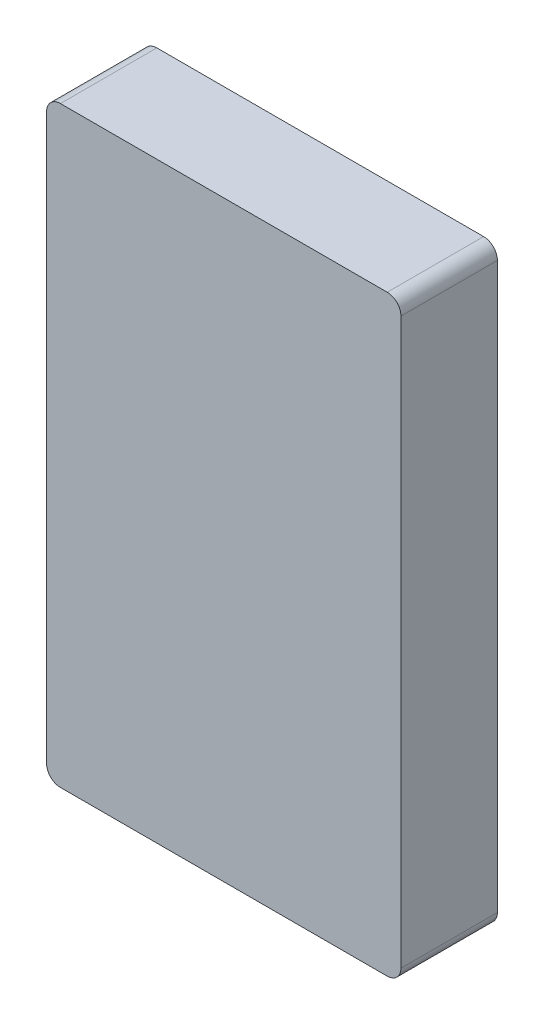
from build123d import *

# Parameters (mm, degrees)
BOSS_EXTRUDE2_DEPTH = 44.45
SKETCH3_R           = 1.5875
CUT_EXTRUDE1_DEPTH  = 6.35


with BuildPart() as part:
    # Model → Boss-Extrude2 (new body)
    with BuildSketch(Plane.XY):
        with BuildLine():
            Line((-114.7858004, -1481.0994), (-114.7858004, -1220.7494))
            ThreePointArc((-114.7858004, -1220.7494), (-116.645672339, -1216.259271939), (-121.1358004, -1214.3994))
            Line((-121.1358004, -1214.3994), (-271.8000406, -1214.3994))
            ThreePointArc((-271.8000406, -1214.3994), (-276.290168661, -1216.259271939), (-278.1500406, -1220.7494))
            Line((-278.1500406, -1220.7494), (-278.1500406, -1481.0994))
            ThreePointArc((-278.1500406, -1481.0994), (-276.290168661, -1485.589528061), (-271.8000406, -1487.4494))
            Line((-271.8000406, -1487.4494), (-121.1358004, -1487.4494))
            ThreePointArc((-121.1358004, -1487.4494), (-116.645672339, -1485.589528061), (-114.7858004, -1481.0994))
        make_face()
    extrude(amount=BOSS_EXTRUDE2_DEPTH)

    # Sketch3 → Cut-Extrude1 (cut)
    with BuildSketch(Plane(origin=(0, 0, 0), x_dir=(-1, 0, 0), z_dir=(0, 0, -1))):
        with Locations((187.835413, -1275.2256944)):
            Circle(SKETCH3_R)
        with Locations((181.485413, -1275.2256944)):
            Circle(SKETCH3_R)
        with Locations((194.185413, -1275.2256944)):
            Circle(SKETCH3_R)
        with Locations((187.835413, -1268.8756944)):
            Circle(SKETCH3_R)
        with Locations((181.485413, -1268.8756944)):
            Circle(SKETCH3_R)
        with Locations((194.185413, -1268.8756944)):
            Circle(SKETCH3_R)
        with Locations((187.835413, -1262.5256944)):
            Circle(SKETCH3_R)
        with Locations((181.485413, -1262.5256944)):
            Circle(SKETCH3_R)
        with Locations((194.185413, -1262.5256944)):
            Circle(SKETCH3_R)
        with Locations((187.835413, -1256.1756944)):
            Circle(SKETCH3_R)
        with Locations((181.485413, -1256.1756944)):
            Circle(SKETCH3_R)
        with Locations((194.185413, -1256.1756944)):
            Circle(SKETCH3_R)
        with Locations((187.835413, -1281.5756944)):
            Circle(SKETCH3_R)
        with Locations((181.485413, -1281.5756944)):
            Circle(SKETCH3_R)
        with Locations((194.185413, -1281.5756944)):
            Circle(SKETCH3_R)
        with Locations((132.3624226, -1274.5006514)):
            Circle(SKETCH3_R)
        with Locations((126.0124226, -1274.5006514)):
            Circle(SKETCH3_R)
        with Locations((138.7124226, -1274.5006514)):
            Circle(SKETCH3_R)
        with Locations((132.3624226, -1268.1506514)):
            Circle(SKETCH3_R)
        with Locations((126.0124226, -1268.1506514)):
            Circle(SKETCH3_R)
        with Locations((138.7124226, -1268.1506514)):
            Circle(SKETCH3_R)
        with Locations((132.3624226, -1261.8006514)):
            Circle(SKETCH3_R)
        with Locations((126.0124226, -1261.8006514)):
            Circle(SKETCH3_R)
        with Locations((138.7124226, -1261.8006514)):
            Circle(SKETCH3_R)
        with Locations((132.3624226, -1255.4506514)):
            Circle(SKETCH3_R)
        with Locations((126.0124226, -1255.4506514)):
            Circle(SKETCH3_R)
        with Locations((138.7124226, -1255.4506514)):
            Circle(SKETCH3_R)
        with Locations((132.3624226, -1280.8506514)):
            Circle(SKETCH3_R)
        with Locations((126.0124226, -1280.8506514)):
            Circle(SKETCH3_R)
        with Locations((138.7124226, -1280.8506514)):
            Circle(SKETCH3_R)
        with Locations((262.0453992, -1275.2256944)):
            Circle(SKETCH3_R)
        with Locations((255.6953992, -1275.2256944)):
            Circle(SKETCH3_R)
        with Locations((268.3953992, -1275.2256944)):
            Circle(SKETCH3_R)
        with Locations((262.0453992, -1268.8756944)):
            Circle(SKETCH3_R)
        with Locations((255.6953992, -1268.8756944)):
            Circle(SKETCH3_R)
        with Locations((268.3953992, -1268.8756944)):
            Circle(SKETCH3_R)
        with Locations((262.0453992, -1262.5256944)):
            Circle(SKETCH3_R)
        with Locations((255.6953992, -1262.5256944)):
            Circle(SKETCH3_R)
        with Locations((268.3953992, -1262.5256944)):
            Circle(SKETCH3_R)
        with Locations((262.0453992, -1256.1756944)):
            Circle(SKETCH3_R)
        with Locations((255.6953992, -1256.1756944)):
            Circle(SKETCH3_R)
        with Locations((268.3953992, -1256.1756944)):
            Circle(SKETCH3_R)
        with Locations((262.0453992, -1281.5756944)):
            Circle(SKETCH3_R)
        with Locations((255.6953992, -1281.5756944)):
            Circle(SKETCH3_R)
        with Locations((268.3953992, -1281.5756944)):
            Circle(SKETCH3_R)
        with Locations((211.081112, -1476.7057842)):
            Circle(SKETCH3_R)
        with Locations((211.71535, -1470.3875596)):
            Circle(SKETCH3_R)
        with Locations((210.446874, -1483.0240342)):
            Circle(SKETCH3_R)
        with Locations((218.06535, -1476.7375596)):
            Circle(SKETCH3_R)
        with Locations((218.06535, -1470.3875596)):
            Circle(SKETCH3_R)
        with Locations((218.06535, -1483.0875596)):
            Circle(SKETCH3_R)
        with Locations((229.0370832, -1476.2635702)):
            Circle(SKETCH3_R)
        with Locations((229.0370832, -1469.9135702)):
            Circle(SKETCH3_R)
        with Locations((229.0370832, -1482.6135702)):
            Circle(SKETCH3_R)
        with Locations((235.913549, -1476.2417008)):
            Circle(SKETCH3_R)
        with Locations((235.3870832, -1469.9135702)):
            Circle(SKETCH3_R)
        with Locations((236.4399894, -1482.5698314)):
            Circle(SKETCH3_R)
        with Locations((203.8965442, -1475.3608034)):
            Circle(SKETCH3_R)
        with Locations((205.36535, -1469.1830154)):
            Circle(SKETCH3_R)
        with Locations((202.4277638, -1481.5385914)):
            Circle(SKETCH3_R)
        with Locations((222.2470536, -1226.1652896)):
            Circle(SKETCH3_R)
        with Locations((222.2470536, -1232.5152896)):
            Circle(SKETCH3_R)
        with Locations((222.2470536, -1219.8152896)):
            Circle(SKETCH3_R)
        with Locations((215.8970536, -1226.1652896)):
            Circle(SKETCH3_R)
        with Locations((215.8970536, -1232.5152896)):
            Circle(SKETCH3_R)
        with Locations((215.8970536, -1219.8152896)):
            Circle(SKETCH3_R)
        with Locations((209.5470536, -1226.1652896)):
            Circle(SKETCH3_R)
        with Locations((209.5470536, -1232.5152896)):
            Circle(SKETCH3_R)
        with Locations((209.5470536, -1219.8152896)):
            Circle(SKETCH3_R)
        with Locations((203.1970536, -1226.1652896)):
            Circle(SKETCH3_R)
        with Locations((203.1970536, -1232.5152896)):
            Circle(SKETCH3_R)
        with Locations((203.1970536, -1219.8152896)):
            Circle(SKETCH3_R)
        with Locations((228.5970536, -1226.1652896)):
            Circle(SKETCH3_R)
        with Locations((228.5970536, -1232.5152896)):
            Circle(SKETCH3_R)
        with Locations((228.5970536, -1219.8152896)):
            Circle(SKETCH3_R)
        with Locations((186.1002882, -1226.4472042)):
            Circle(SKETCH3_R)
        with Locations((186.1002882, -1232.7972042)):
            Circle(SKETCH3_R)
        with Locations((186.1002882, -1220.0972042)):
            Circle(SKETCH3_R)
        with Locations((179.7502882, -1226.4472042)):
            Circle(SKETCH3_R)
        with Locations((179.7502882, -1232.7972042)):
            Circle(SKETCH3_R)
        with Locations((179.7502882, -1220.0972042)):
            Circle(SKETCH3_R)
        with Locations((173.4002882, -1226.4472042)):
            Circle(SKETCH3_R)
        with Locations((173.4002882, -1232.7972042)):
            Circle(SKETCH3_R)
        with Locations((173.4002882, -1220.0972042)):
            Circle(SKETCH3_R)
        with Locations((167.0502882, -1226.4472042)):
            Circle(SKETCH3_R)
        with Locations((167.0502882, -1232.7972042)):
            Circle(SKETCH3_R)
        with Locations((167.0502882, -1220.0972042)):
            Circle(SKETCH3_R)
        with Locations((192.4502882, -1226.4472042)):
            Circle(SKETCH3_R)
        with Locations((192.4502882, -1232.7972042)):
            Circle(SKETCH3_R)
        with Locations((192.4502882, -1220.0972042)):
            Circle(SKETCH3_R)
        with Locations((187.835413, -1309.4276326)):
            Circle(SKETCH3_R)
        with Locations((181.485413, -1309.4276326)):
            Circle(SKETCH3_R)
        with Locations((194.185413, -1309.4276326)):
            Circle(SKETCH3_R)
        with Locations((187.835413, -1303.0776326)):
            Circle(SKETCH3_R)
        with Locations((181.485413, -1303.0776326)):
            Circle(SKETCH3_R)
        with Locations((194.185413, -1303.0776326)):
            Circle(SKETCH3_R)
        with Locations((187.835413, -1296.7276326)):
            Circle(SKETCH3_R)
        with Locations((181.485413, -1296.7276326)):
            Circle(SKETCH3_R)
        with Locations((194.185413, -1296.7276326)):
            Circle(SKETCH3_R)
        with Locations((187.835413, -1290.3776326)):
            Circle(SKETCH3_R)
        with Locations((181.485413, -1290.3776326)):
            Circle(SKETCH3_R)
        with Locations((194.185413, -1290.3776326)):
            Circle(SKETCH3_R)
        with Locations((187.835413, -1315.7776326)):
            Circle(SKETCH3_R)
        with Locations((181.485413, -1315.7776326)):
            Circle(SKETCH3_R)
        with Locations((194.185413, -1315.7776326)):
            Circle(SKETCH3_R)
        with Locations((132.3624226, -1308.7025896)):
            Circle(SKETCH3_R)
        with Locations((126.0124226, -1308.7025896)):
            Circle(SKETCH3_R)
        with Locations((138.7124226, -1308.7025896)):
            Circle(SKETCH3_R)
        with Locations((132.3624226, -1302.3525896)):
            Circle(SKETCH3_R)
        with Locations((126.0124226, -1302.3525896)):
            Circle(SKETCH3_R)
        with Locations((138.7124226, -1302.3525896)):
            Circle(SKETCH3_R)
        with Locations((132.3624226, -1296.0025896)):
            Circle(SKETCH3_R)
        with Locations((126.0124226, -1296.0025896)):
            Circle(SKETCH3_R)
        with Locations((138.7124226, -1296.0025896)):
            Circle(SKETCH3_R)
        with Locations((132.3624226, -1289.6525896)):
            Circle(SKETCH3_R)
        with Locations((126.0124226, -1289.6525896)):
            Circle(SKETCH3_R)
        with Locations((138.7124226, -1289.6525896)):
            Circle(SKETCH3_R)
        with Locations((132.3624226, -1315.0525896)):
            Circle(SKETCH3_R)
        with Locations((126.0124226, -1315.0525896)):
            Circle(SKETCH3_R)
        with Locations((138.7124226, -1315.0525896)):
            Circle(SKETCH3_R)
        with Locations((262.0453992, -1309.4276326)):
            Circle(SKETCH3_R)
        with Locations((255.6953992, -1309.4276326)):
            Circle(SKETCH3_R)
        with Locations((268.3953992, -1309.4276326)):
            Circle(SKETCH3_R)
        with Locations((262.0453992, -1303.0776326)):
            Circle(SKETCH3_R)
        with Locations((255.6953992, -1303.0776326)):
            Circle(SKETCH3_R)
        with Locations((268.3953992, -1303.0776326)):
            Circle(SKETCH3_R)
        with Locations((262.0453992, -1296.7276326)):
            Circle(SKETCH3_R)
        with Locations((255.6953992, -1296.7276326)):
            Circle(SKETCH3_R)
        with Locations((268.3953992, -1296.7276326)):
            Circle(SKETCH3_R)
        with Locations((262.0453992, -1290.3776326)):
            Circle(SKETCH3_R)
        with Locations((255.6953992, -1290.3776326)):
            Circle(SKETCH3_R)
        with Locations((268.3953992, -1290.3776326)):
            Circle(SKETCH3_R)
        with Locations((262.0453992, -1315.7776326)):
            Circle(SKETCH3_R)
        with Locations((255.6953992, -1315.7776326)):
            Circle(SKETCH3_R)
        with Locations((268.3953992, -1315.7776326)):
            Circle(SKETCH3_R)
        with Locations((187.835413, -1344.9876326)):
            Circle(SKETCH3_R)
        with Locations((181.485413, -1344.9876326)):
            Circle(SKETCH3_R)
        with Locations((194.185413, -1344.9876326)):
            Circle(SKETCH3_R)
        with Locations((187.835413, -1338.6376326)):
            Circle(SKETCH3_R)
        with Locations((181.485413, -1338.6376326)):
            Circle(SKETCH3_R)
        with Locations((194.185413, -1338.6376326)):
            Circle(SKETCH3_R)
        with Locations((187.835413, -1332.2876326)):
            Circle(SKETCH3_R)
        with Locations((181.485413, -1332.2876326)):
            Circle(SKETCH3_R)
        with Locations((194.185413, -1332.2876326)):
            Circle(SKETCH3_R)
        with Locations((187.835413, -1325.9376326)):
            Circle(SKETCH3_R)
        with Locations((181.485413, -1325.9376326)):
            Circle(SKETCH3_R)
        with Locations((194.185413, -1325.9376326)):
            Circle(SKETCH3_R)
        with Locations((187.835413, -1351.3376326)):
            Circle(SKETCH3_R)
        with Locations((181.485413, -1351.3376326)):
            Circle(SKETCH3_R)
        with Locations((194.185413, -1351.3376326)):
            Circle(SKETCH3_R)
        with Locations((132.3624226, -1344.2625896)):
            Circle(SKETCH3_R)
        with Locations((126.0124226, -1344.2625896)):
            Circle(SKETCH3_R)
        with Locations((138.7124226, -1344.2625896)):
            Circle(SKETCH3_R)
        with Locations((132.3624226, -1337.9125896)):
            Circle(SKETCH3_R)
        with Locations((126.0124226, -1337.9125896)):
            Circle(SKETCH3_R)
        with Locations((138.7124226, -1337.9125896)):
            Circle(SKETCH3_R)
        with Locations((132.3624226, -1331.5625896)):
            Circle(SKETCH3_R)
        with Locations((126.0124226, -1331.5625896)):
            Circle(SKETCH3_R)
        with Locations((138.7124226, -1331.5625896)):
            Circle(SKETCH3_R)
        with Locations((132.3624226, -1325.2125896)):
            Circle(SKETCH3_R)
        with Locations((126.0124226, -1325.2125896)):
            Circle(SKETCH3_R)
        with Locations((138.7124226, -1325.2125896)):
            Circle(SKETCH3_R)
        with Locations((132.3624226, -1350.6125896)):
            Circle(SKETCH3_R)
        with Locations((126.0124226, -1350.6125896)):
            Circle(SKETCH3_R)
        with Locations((138.7124226, -1350.6125896)):
            Circle(SKETCH3_R)
        with Locations((262.0453992, -1344.9876326)):
            Circle(SKETCH3_R)
        with Locations((255.6953992, -1344.9876326)):
            Circle(SKETCH3_R)
        with Locations((268.3953992, -1344.9876326)):
            Circle(SKETCH3_R)
        with Locations((262.0453992, -1338.6376326)):
            Circle(SKETCH3_R)
        with Locations((255.6953992, -1338.6376326)):
            Circle(SKETCH3_R)
        with Locations((268.3953992, -1338.6376326)):
            Circle(SKETCH3_R)
        with Locations((262.0453992, -1332.2876326)):
            Circle(SKETCH3_R)
        with Locations((255.6953992, -1332.2876326)):
            Circle(SKETCH3_R)
        with Locations((268.3953992, -1332.2876326)):
            Circle(SKETCH3_R)
        with Locations((262.0453992, -1325.9376326)):
            Circle(SKETCH3_R)
        with Locations((255.6953992, -1325.9376326)):
            Circle(SKETCH3_R)
        with Locations((268.3953992, -1325.9376326)):
            Circle(SKETCH3_R)
        with Locations((262.0453992, -1351.3376326)):
            Circle(SKETCH3_R)
        with Locations((255.6953992, -1351.3376326)):
            Circle(SKETCH3_R)
        with Locations((268.3953992, -1351.3376326)):
            Circle(SKETCH3_R)
        with Locations((187.835413, -1380.5476326)):
            Circle(SKETCH3_R)
        with Locations((181.485413, -1380.5476326)):
            Circle(SKETCH3_R)
        with Locations((194.185413, -1380.5476326)):
            Circle(SKETCH3_R)
        with Locations((187.835413, -1374.1976326)):
            Circle(SKETCH3_R)
        with Locations((181.485413, -1374.1976326)):
            Circle(SKETCH3_R)
        with Locations((194.185413, -1374.1976326)):
            Circle(SKETCH3_R)
        with Locations((187.835413, -1367.8476326)):
            Circle(SKETCH3_R)
        with Locations((181.485413, -1367.8476326)):
            Circle(SKETCH3_R)
        with Locations((194.185413, -1367.8476326)):
            Circle(SKETCH3_R)
        with Locations((187.835413, -1361.4976326)):
            Circle(SKETCH3_R)
        with Locations((181.485413, -1361.4976326)):
            Circle(SKETCH3_R)
        with Locations((194.185413, -1361.4976326)):
            Circle(SKETCH3_R)
        with Locations((187.835413, -1386.8976326)):
            Circle(SKETCH3_R)
        with Locations((181.485413, -1386.8976326)):
            Circle(SKETCH3_R)
        with Locations((194.185413, -1386.8976326)):
            Circle(SKETCH3_R)
        with Locations((132.3624226, -1379.8225896)):
            Circle(SKETCH3_R)
        with Locations((126.0124226, -1379.8225896)):
            Circle(SKETCH3_R)
        with Locations((138.7124226, -1379.8225896)):
            Circle(SKETCH3_R)
        with Locations((132.3624226, -1373.4725896)):
            Circle(SKETCH3_R)
        with Locations((126.0124226, -1373.4725896)):
            Circle(SKETCH3_R)
        with Locations((138.7124226, -1373.4725896)):
            Circle(SKETCH3_R)
        with Locations((132.3624226, -1367.1225896)):
            Circle(SKETCH3_R)
        with Locations((126.0124226, -1367.1225896)):
            Circle(SKETCH3_R)
        with Locations((138.7124226, -1367.1225896)):
            Circle(SKETCH3_R)
        with Locations((132.3624226, -1360.7725896)):
            Circle(SKETCH3_R)
        with Locations((126.0124226, -1360.7725896)):
            Circle(SKETCH3_R)
        with Locations((138.7124226, -1360.7725896)):
            Circle(SKETCH3_R)
        with Locations((132.3624226, -1386.1725896)):
            Circle(SKETCH3_R)
        with Locations((126.0124226, -1386.1725896)):
            Circle(SKETCH3_R)
        with Locations((138.7124226, -1386.1725896)):
            Circle(SKETCH3_R)
        with Locations((262.0453992, -1380.5476326)):
            Circle(SKETCH3_R)
        with Locations((255.6953992, -1380.5476326)):
            Circle(SKETCH3_R)
        with Locations((268.3953992, -1380.5476326)):
            Circle(SKETCH3_R)
        with Locations((262.0453992, -1374.1976326)):
            Circle(SKETCH3_R)
        with Locations((255.6953992, -1374.1976326)):
            Circle(SKETCH3_R)
        with Locations((268.3953992, -1374.1976326)):
            Circle(SKETCH3_R)
        with Locations((262.0453992, -1367.8476326)):
            Circle(SKETCH3_R)
        with Locations((255.6953992, -1367.8476326)):
            Circle(SKETCH3_R)
        with Locations((268.3953992, -1367.8476326)):
            Circle(SKETCH3_R)
        with Locations((262.0453992, -1361.4976326)):
            Circle(SKETCH3_R)
        with Locations((255.6953992, -1361.4976326)):
            Circle(SKETCH3_R)
        with Locations((268.3953992, -1361.4976326)):
            Circle(SKETCH3_R)
        with Locations((262.0453992, -1386.8976326)):
            Circle(SKETCH3_R)
        with Locations((255.6953992, -1386.8976326)):
            Circle(SKETCH3_R)
        with Locations((268.3953992, -1386.8976326)):
            Circle(SKETCH3_R)
        with Locations((187.835413, -1416.1076326)):
            Circle(SKETCH3_R)
        with Locations((181.485413, -1416.1076326)):
            Circle(SKETCH3_R)
        with Locations((194.185413, -1416.1076326)):
            Circle(SKETCH3_R)
        with Locations((187.835413, -1409.7576326)):
            Circle(SKETCH3_R)
        with Locations((181.485413, -1409.7576326)):
            Circle(SKETCH3_R)
        with Locations((194.185413, -1409.7576326)):
            Circle(SKETCH3_R)
        with Locations((187.835413, -1403.4076326)):
            Circle(SKETCH3_R)
        with Locations((181.485413, -1403.4076326)):
            Circle(SKETCH3_R)
        with Locations((194.185413, -1403.4076326)):
            Circle(SKETCH3_R)
        with Locations((187.835413, -1397.0576326)):
            Circle(SKETCH3_R)
        with Locations((181.485413, -1397.0576326)):
            Circle(SKETCH3_R)
        with Locations((194.185413, -1397.0576326)):
            Circle(SKETCH3_R)
        with Locations((187.835413, -1422.4576326)):
            Circle(SKETCH3_R)
        with Locations((181.485413, -1422.4576326)):
            Circle(SKETCH3_R)
        with Locations((194.185413, -1422.4576326)):
            Circle(SKETCH3_R)
        with Locations((132.3624226, -1415.3825896)):
            Circle(SKETCH3_R)
        with Locations((126.0124226, -1415.3825896)):
            Circle(SKETCH3_R)
        with Locations((138.7124226, -1415.3825896)):
            Circle(SKETCH3_R)
        with Locations((132.3624226, -1409.0325896)):
            Circle(SKETCH3_R)
        with Locations((126.0124226, -1409.0325896)):
            Circle(SKETCH3_R)
        with Locations((138.7124226, -1409.0325896)):
            Circle(SKETCH3_R)
        with Locations((132.3624226, -1402.6825896)):
            Circle(SKETCH3_R)
        with Locations((126.0124226, -1402.6825896)):
            Circle(SKETCH3_R)
        with Locations((138.7124226, -1402.6825896)):
            Circle(SKETCH3_R)
        with Locations((132.3624226, -1396.3325896)):
            Circle(SKETCH3_R)
        with Locations((126.0124226, -1396.3325896)):
            Circle(SKETCH3_R)
        with Locations((138.7124226, -1396.3325896)):
            Circle(SKETCH3_R)
        with Locations((132.3624226, -1421.7325896)):
            Circle(SKETCH3_R)
        with Locations((126.0124226, -1421.7325896)):
            Circle(SKETCH3_R)
        with Locations((138.7124226, -1421.7325896)):
            Circle(SKETCH3_R)
        with Locations((262.0453992, -1416.1076326)):
            Circle(SKETCH3_R)
        with Locations((255.6953992, -1416.1076326)):
            Circle(SKETCH3_R)
        with Locations((268.3953992, -1416.1076326)):
            Circle(SKETCH3_R)
        with Locations((262.0453992, -1409.7576326)):
            Circle(SKETCH3_R)
        with Locations((255.6953992, -1409.7576326)):
            Circle(SKETCH3_R)
        with Locations((268.3953992, -1409.7576326)):
            Circle(SKETCH3_R)
        with Locations((262.0453992, -1403.4076326)):
            Circle(SKETCH3_R)
        with Locations((255.6953992, -1403.4076326)):
            Circle(SKETCH3_R)
        with Locations((268.3953992, -1403.4076326)):
            Circle(SKETCH3_R)
        with Locations((262.0453992, -1397.0576326)):
            Circle(SKETCH3_R)
        with Locations((255.6953992, -1397.0576326)):
            Circle(SKETCH3_R)
        with Locations((268.3953992, -1397.0576326)):
            Circle(SKETCH3_R)
        with Locations((262.0453992, -1422.4576326)):
            Circle(SKETCH3_R)
        with Locations((255.6953992, -1422.4576326)):
            Circle(SKETCH3_R)
        with Locations((268.3953992, -1422.4576326)):
            Circle(SKETCH3_R)
        with Locations((187.835413, -1451.6676326)):
            Circle(SKETCH3_R)
        with Locations((181.485413, -1451.6676326)):
            Circle(SKETCH3_R)
        with Locations((194.185413, -1451.6676326)):
            Circle(SKETCH3_R)
        with Locations((187.835413, -1445.3176326)):
            Circle(SKETCH3_R)
        with Locations((181.485413, -1445.3176326)):
            Circle(SKETCH3_R)
        with Locations((194.185413, -1445.3176326)):
            Circle(SKETCH3_R)
        with Locations((187.835413, -1438.9676326)):
            Circle(SKETCH3_R)
        with Locations((181.485413, -1438.9676326)):
            Circle(SKETCH3_R)
        with Locations((194.185413, -1438.9676326)):
            Circle(SKETCH3_R)
        with Locations((187.835413, -1432.6176326)):
            Circle(SKETCH3_R)
        with Locations((181.485413, -1432.6176326)):
            Circle(SKETCH3_R)
        with Locations((194.185413, -1432.6176326)):
            Circle(SKETCH3_R)
        with Locations((187.835413, -1458.0176326)):
            Circle(SKETCH3_R)
        with Locations((181.485413, -1458.0176326)):
            Circle(SKETCH3_R)
        with Locations((194.185413, -1458.0176326)):
            Circle(SKETCH3_R)
        with Locations((132.3624226, -1456.3122258)):
            Circle(SKETCH3_R)
        with Locations((126.0124226, -1456.3122258)):
            Circle(SKETCH3_R)
        with Locations((138.7124226, -1456.3122258)):
            Circle(SKETCH3_R)
        with Locations((132.3624226, -1449.9622258)):
            Circle(SKETCH3_R)
        with Locations((126.0124226, -1449.9622258)):
            Circle(SKETCH3_R)
        with Locations((138.7124226, -1449.9622258)):
            Circle(SKETCH3_R)
        with Locations((132.3624226, -1443.6122258)):
            Circle(SKETCH3_R)
        with Locations((126.0124226, -1443.6122258)):
            Circle(SKETCH3_R)
        with Locations((138.7124226, -1443.6122258)):
            Circle(SKETCH3_R)
        with Locations((132.3624226, -1437.2622258)):
            Circle(SKETCH3_R)
        with Locations((126.0124226, -1437.2622258)):
            Circle(SKETCH3_R)
        with Locations((138.7124226, -1437.2622258)):
            Circle(SKETCH3_R)
        with Locations((132.3624226, -1462.6622258)):
            Circle(SKETCH3_R)
        with Locations((126.0124226, -1462.6622258)):
            Circle(SKETCH3_R)
        with Locations((138.7124226, -1462.6622258)):
            Circle(SKETCH3_R)
        with Locations((262.0453992, -1451.6676326)):
            Circle(SKETCH3_R)
        with Locations((255.6953992, -1451.6676326)):
            Circle(SKETCH3_R)
        with Locations((268.3953992, -1451.6676326)):
            Circle(SKETCH3_R)
        with Locations((262.0453992, -1445.3176326)):
            Circle(SKETCH3_R)
        with Locations((255.6953992, -1445.3176326)):
            Circle(SKETCH3_R)
        with Locations((268.3953992, -1445.3176326)):
            Circle(SKETCH3_R)
        with Locations((262.0453992, -1438.9676326)):
            Circle(SKETCH3_R)
        with Locations((255.6953992, -1438.9676326)):
            Circle(SKETCH3_R)
        with Locations((268.3953992, -1438.9676326)):
            Circle(SKETCH3_R)
        with Locations((262.0453992, -1432.6176326)):
            Circle(SKETCH3_R)
        with Locations((255.6953992, -1432.6176326)):
            Circle(SKETCH3_R)
        with Locations((268.3953992, -1432.6176326)):
            Circle(SKETCH3_R)
        with Locations((262.0453992, -1458.0176326)):
            Circle(SKETCH3_R)
        with Locations((255.6953992, -1458.0176326)):
            Circle(SKETCH3_R)
        with Locations((268.3953992, -1458.0176326)):
            Circle(SKETCH3_R)
        with Locations((132.3624226, -1474.1108948)):
            Circle(SKETCH3_R)
        with Locations((126.0124226, -1474.1108948)):
            Circle(SKETCH3_R)
        with Locations((138.7124226, -1474.1108948)):
            Circle(SKETCH3_R)
        with Locations((132.3624226, -1480.4608948)):
            Circle(SKETCH3_R)
        with Locations((126.0124226, -1480.4608948)):
            Circle(SKETCH3_R)
        with Locations((138.7124226, -1480.4608948)):
            Circle(SKETCH3_R)
        with Locations((186.75985, -1472.7606816)):
            Circle(SKETCH3_R)
        with Locations((191.165099, -1467.971283)):
            Circle(SKETCH3_R)
        with Locations((195.570348, -1463.1819098)):
            Circle(SKETCH3_R)
        with Locations((200.012808, -1467.7353932)):
            Circle(SKETCH3_R)
        with Locations((196.5699142, -1473.5105658)):
            Circle(SKETCH3_R)
        with Locations((193.3491434, -1478.8414924)):
            Circle(SKETCH3_R)
        with Locations((242.2311386, -1469.5123772)):
            Circle(SKETCH3_R)
        with Locations((243.7697182, -1475.768448)):
            Circle(SKETCH3_R)
        with Locations((245.1164008, -1482.1821512)):
            Circle(SKETCH3_R)
        with Locations((255.1142218, -1478.7304436)):
            Circle(SKETCH3_R)
        with Locations((251.7823768, -1473.5105658)):
            Circle(SKETCH3_R)
        with Locations((248.5616314, -1468.5128364)):
            Circle(SKETCH3_R)
        with Locations((253.448312, -1463.7372046)):
            Circle(SKETCH3_R)
        with Locations((257.957193, -1468.4970376)):
            Circle(SKETCH3_R)
        with Locations((262.5192362, -1473.750672)):
            Circle(SKETCH3_R)
        with Locations((187.828555, -1247.8396938)):
            Circle(SKETCH3_R)
        with Locations((238.9295704, -1220.4933172)):
            Circle(SKETCH3_R)
        with Locations((237.9856556, -1227.4152998)):
            Circle(SKETCH3_R)
        with Locations((237.0417408, -1233.5506698)):
            Circle(SKETCH3_R)
        with Locations((248.2906388, -1223.222979)):
            Circle(SKETCH3_R)
        with Locations((245.6162474, -1229.3583744)):
            Circle(SKETCH3_R)
        with Locations((242.7845284, -1235.3364422)):
            Circle(SKETCH3_R)
        with Locations((257.1953708, -1228.753194)):
            Circle(SKETCH3_R)
        with Locations((252.4758476, -1233.4727172)):
            Circle(SKETCH3_R)
        with Locations((247.9136266, -1238.3495426)):
            Circle(SKETCH3_R)
        with Locations((263.2683838, -1235.3534094)):
            Circle(SKETCH3_R)
        with Locations((257.4476436, -1239.2863454)):
            Circle(SKETCH3_R)
        with Locations((251.9415332, -1242.4326942)):
            Circle(SKETCH3_R)
        with Locations((255.772412, -1248.348405)):
            Circle(SKETCH3_R)
        with Locations((261.5931522, -1244.8874264)):
            Circle(SKETCH3_R)
        with Locations((268.200505, -1242.3703372)):
            Circle(SKETCH3_R)
        with Locations((156.2602158, -1220.7433548)):
            Circle(SKETCH3_R)
        with Locations((157.2041306, -1227.665312)):
            Circle(SKETCH3_R)
        with Locations((158.14802, -1233.8007074)):
            Circle(SKETCH3_R)
        with Locations((146.899122, -1223.4730166)):
            Circle(SKETCH3_R)
        with Locations((149.5735388, -1229.608412)):
            Circle(SKETCH3_R)
        with Locations((152.4052578, -1235.5864544)):
            Circle(SKETCH3_R)
        with Locations((137.9944154, -1229.0032062)):
            Circle(SKETCH3_R)
        with Locations((142.7139386, -1233.7227294)):
            Circle(SKETCH3_R)
        with Locations((147.2761342, -1238.5995802)):
            Circle(SKETCH3_R)
        with Locations((131.9214024, -1235.603447)):
            Circle(SKETCH3_R)
        with Locations((137.7421426, -1239.536383)):
            Circle(SKETCH3_R)
        with Locations((143.248253, -1242.6827318)):
            Circle(SKETCH3_R)
        with Locations((139.4173742, -1248.5984426)):
            Circle(SKETCH3_R)
        with Locations((133.5966086, -1245.1374386)):
            Circle(SKETCH3_R)
        with Locations((126.9892812, -1242.6203748)):
            Circle(SKETCH3_R)
    extrude(amount=-CUT_EXTRUDE1_DEPTH, mode=Mode.SUBTRACT)


solid = part.part
